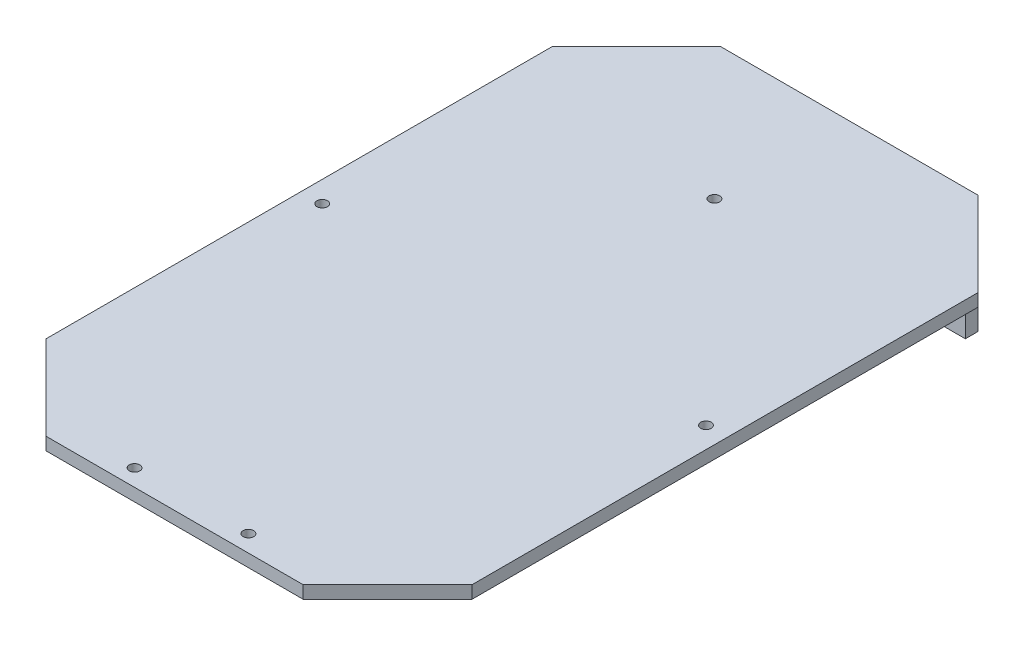
from build123d import *

# Parameters (mm, degrees)
ESBO_O1_W                = 101
ESBO_O1_H                = 160
RESSALTO_EXTRUS_O1_DEPTH = 3
ESBO_O2_R                = 1.25
CORTE_EXTRUS_O1_DEPTH    = 140
CHANFRO1_SIZE            = 20
ESBO_O3_W                = 61
ESBO_O3_H                = 3
RESSALTO_EXTRUS_O2_DEPTH = 25
ESBO_O4_R                = 0.5
CORTE_EXTRUS_O2_DEPTH    = 25


with BuildPart() as part:
    # Esboço1 → Ressalto-extrusão1 (new body)
    with BuildSketch(Plane(origin=(0, 0, 0), x_dir=(1, 0, 0), z_dir=(0, 1, 0))):
        with Locations((-30.270258535, -22.046326637)):
            Rectangle(ESBO_O1_W, ESBO_O1_H)
    extrude(amount=RESSALTO_EXTRUS_O1_DEPTH)

    # Esboço2 → Corte-extrusão1 (cut)
    with BuildSketch(Plane(origin=(0, 3, 0), x_dir=(1, 0, 0), z_dir=(0, 1, 0))):
        with Locations((15.229741465, -21.546326637)):
            Circle(ESBO_O2_R)
        with Locations((-75.770258535, -21.546326637)):
            Circle(ESBO_O2_R)
        with Locations((-30.270258535, 25.953673363)):
            Circle(ESBO_O2_R)
        with Locations((-43.770258535, -98.046326637)):
            Circle(ESBO_O2_R)
        with Locations((-16.770258535, -98.046326637)):
            Circle(ESBO_O2_R)
    extrude(amount=-CORTE_EXTRUS_O1_DEPTH, mode=Mode.SUBTRACT)

    # Chanfro1
    chanfro1_edges = [part.edges().sort_by_distance(p)[0] for p in [
        (-80.770258535, 1.5, -57.953673363),
        (20.229741465, 1.5, -57.953673363),
        (20.229741465, 1.5, 102.046326637),
        (-80.770258535, 1.5, 102.046326637),
    ]]
    chamfer(chanfro1_edges, length=CHANFRO1_SIZE)

    # Esboço3 → Ressalto-extrusão2 (add)
    with BuildSketch(Plane.XZ):
        with Locations((-30.270258535, -56.453673363)):
            Rectangle(ESBO_O3_W, ESBO_O3_H)
    extrude(amount=RESSALTO_EXTRUS_O2_DEPTH)

    # Esboço4 → Corte-extrusão2 (cut)
    with BuildSketch(Plane(origin=(0, 0, -57.953673363), x_dir=(-1, 0, 0), z_dir=(0, 0, -1))):
        with Locations((9.770258535, -5.5)):
            Circle(ESBO_O4_R)
        with Locations((50.770258535, -21)):
            Circle(ESBO_O4_R)
        with Locations((9.770258535, -21)):
            Circle(ESBO_O4_R)
        with Locations((50.770258535, -5.5)):
            Circle(ESBO_O4_R)
    extrude(amount=-CORTE_EXTRUS_O2_DEPTH, mode=Mode.SUBTRACT)


solid = part.part
